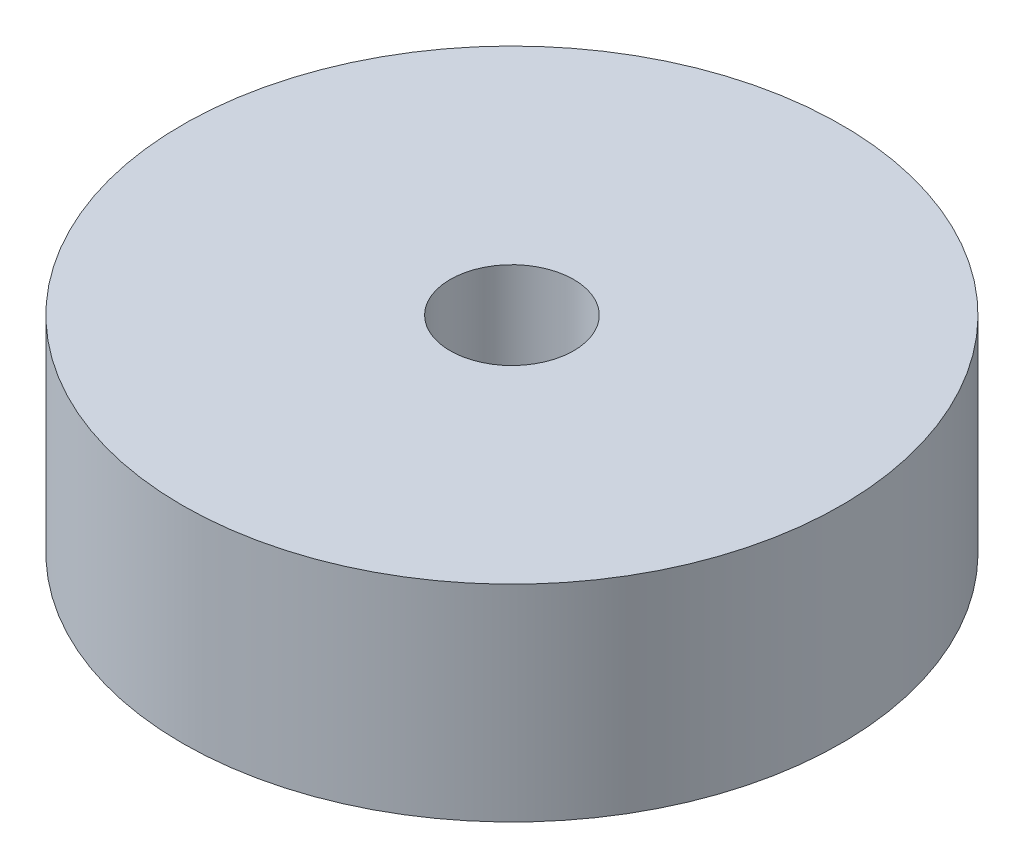
from build123d import *

# Parameters (mm, degrees)
SKETCH2_R          = 4.7625
CUT_EXTRUDE1_DEPTH = 28.702


with BuildPart() as part:
    # Sketch1 → Revolve2 (revolve)
    with BuildSketch(Plane.XY):
        Polygon((0, 22.225), (1.27, 22.225), (1.27, 25.4), (25.4, 25.4), (25.4, 9.525), (9.525, 9.525), (9.525, 0), (0, 0), align=None)
    revolve(axis=Axis((0, 41.306029029, 0), (0, -1, 0)))

    # Sketch2 → Cut-Extrude1 (cut)
    with BuildSketch(Plane.XZ):
        Circle(SKETCH2_R)
    extrude(amount=-CUT_EXTRUDE1_DEPTH, mode=Mode.SUBTRACT)


solid = part.part
